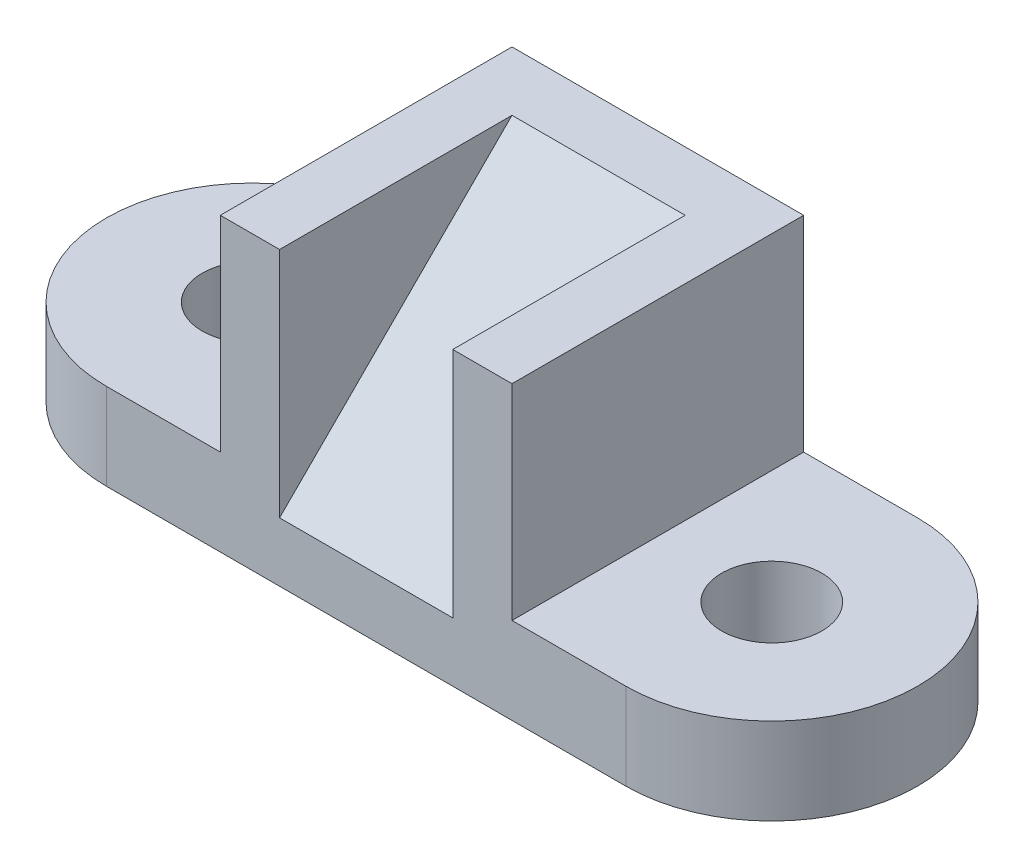
from build123d import *

# Parameters (mm, degrees)
BOSS_EXTRUDE1_DEPTH = 19
SKETCH2_R           = 11
CUT_EXTRUDE1_DEPTH  = 19
SKETCH3_W           = 64
SKETCH3_H           = 64
BOSS_EXTRUDE2_DEPTH = 45
SKETCH10_W          = 38
SKETCH10_H          = 51
CUT_EXTRUDE2_DEPTH  = 51
BOSS_EXTRUDE3_DEPTH = 38


with BuildPart() as part:
    # Sketch1 → Boss-Extrude1 (new body)
    with BuildSketch(Plane(origin=(0, 0, 0), x_dir=(1, 0, 0), z_dir=(0, 1, 0))):
        with BuildLine():
            Line((0, 32), (114, 32))
            ThreePointArc((114, 32), (146, 0), (114, -32))
            Line((114, -32), (0, -32))
            ThreePointArc((0, -32), (-32, 0), (0, 32))
        make_face()
    extrude(amount=BOSS_EXTRUDE1_DEPTH)

    # Sketch2 → Cut-Extrude1 (cut)
    with BuildSketch(Plane(origin=(0, 19, 0), x_dir=(1, 0, 0), z_dir=(0, 1, 0))):
        Circle(SKETCH2_R)
        with Locations((114, 0)):
            Circle(SKETCH2_R)
    extrude(amount=-CUT_EXTRUDE1_DEPTH, mode=Mode.SUBTRACT)

    # Sketch3 → Boss-Extrude2 (add)
    with BuildSketch(Plane(origin=(0, 19, 0), x_dir=(1, 0, 0), z_dir=(0, 1, 0))):
        with Locations((57, 0)):
            Rectangle(SKETCH3_W, SKETCH3_H)
    extrude(amount=BOSS_EXTRUDE2_DEPTH)

    # Sketch10 → Cut-Extrude2 (cut)
    with BuildSketch(Plane(origin=(0, 64, 0), x_dir=(1, 0, 0), z_dir=(0, 1, 0))):
        with Locations((57, -6.5)):
            Rectangle(SKETCH10_W, SKETCH10_H)
    extrude(amount=-CUT_EXTRUDE2_DEPTH, mode=Mode.SUBTRACT)

    # Sketch11 → Boss-Extrude3 (add)
    with BuildSketch(Plane.ZY.offset(-76)):
        Polygon((-19, 64), (32, 13), (-19, 13), align=None)
    extrude(amount=BOSS_EXTRUDE3_DEPTH)


solid = part.part
